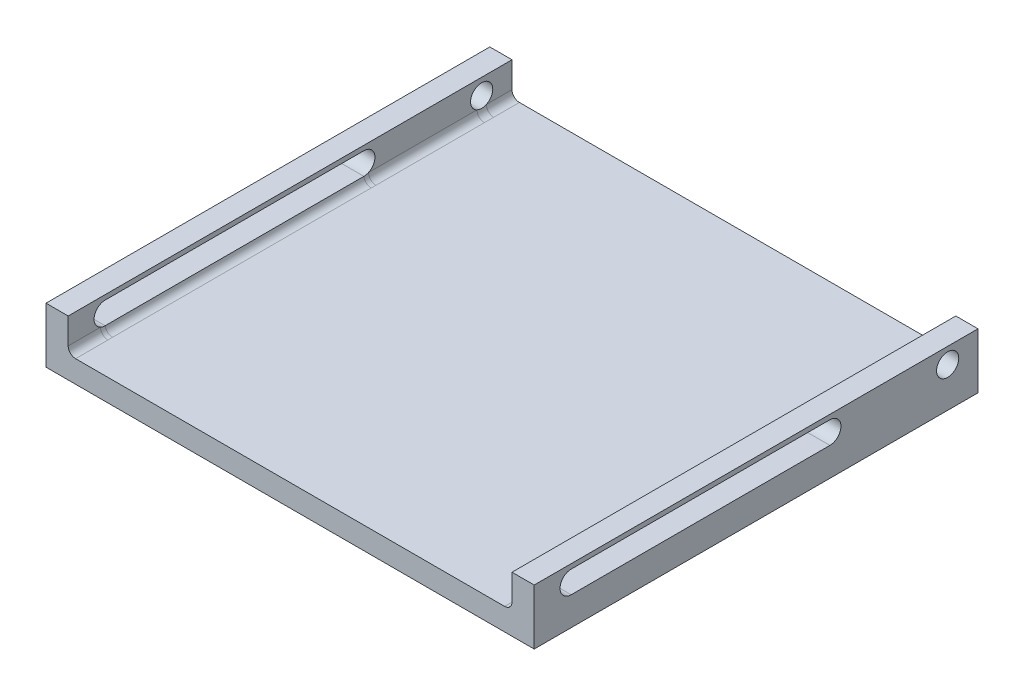
from build123d import *

# Parameters (mm, degrees)
SKETCH1_W           = 600
SKETCH1_H           = 600
BOSS_EXTRUDE1_DEPTH = 30
SKETCH2_W           = 600
SKETCH2_H           = 75
SKETCH2_R           = 15
BOSS_EXTRUDE2_DEPTH = 30
CUT_EXTRUDE4_START  = -631
CUT_EXTRUDE4_DEPTH  = 661
FILLET1_R           = 10


with BuildPart() as part:
    # Sketch1 → Boss-Extrude1 (new body)
    with BuildSketch(Plane(origin=(0, 0, 0), x_dir=(1, 0, 0), z_dir=(0, 1, 0))):
        Rectangle(SKETCH1_W, SKETCH1_H)
    extrude(amount=BOSS_EXTRUDE1_DEPTH)

    # Sketch2 → Boss-Extrude2 (add)
    with BuildSketch(Plane(origin=(300, 0, 0), x_dir=(0, 0, -1), z_dir=(1, 0, 0))):
        with Locations((0, 37.5)):
            Rectangle(SKETCH2_W, SKETCH2_H)
        with Locations((258.993384408, 53.607709477)):
            Circle(SKETCH2_R, mode=Mode.SUBTRACT)
    boss_extrude2 = extrude(amount=BOSS_EXTRUDE2_DEPTH)

    # Sketch3 → Cut-Extrude4 (cut)
    with BuildSketch(Plane(origin=(330, 0, 0), x_dir=(0, 0, -1), z_dir=(1, 0, 0)).offset(CUT_EXTRUDE4_START)):
        with BuildLine():
            Line((-250, 68.607709477), (99.736599438, 68.607709477))
            ThreePointArc((99.736599438, 68.607709477), (114.736599438, 53.607709477), (99.736599438, 38.607709477))
            Line((99.736599438, 38.607709477), (-250, 38.607709477))
            ThreePointArc((-250, 38.607709477), (-265, 53.607709477), (-250, 68.607709477))
        make_face()
    cut_extrude4 = extrude(amount=CUT_EXTRUDE4_DEPTH, mode=Mode.SUBTRACT)

    # Mirror1: Boss-Extrude2, Cut-Extrude4 across plane
    add(boss_extrude2.mirror(Plane(origin=(0, 0, 0), x_dir=(0, 0, 1), z_dir=(1, 0, 0))))
    add(cut_extrude4.mirror(Plane(origin=(0, 0, 0), x_dir=(0, 0, 1), z_dir=(1, 0, 0))), mode=Mode.SUBTRACT)

    # Fillet1
    fillet1_edges = [part.edges().sort_by_distance(p)[0] for p in [
        (300, 30, 0),
        (-300, 30, 0),
    ]]
    fillet(fillet1_edges, radius=FILLET1_R)


solid = part.part
